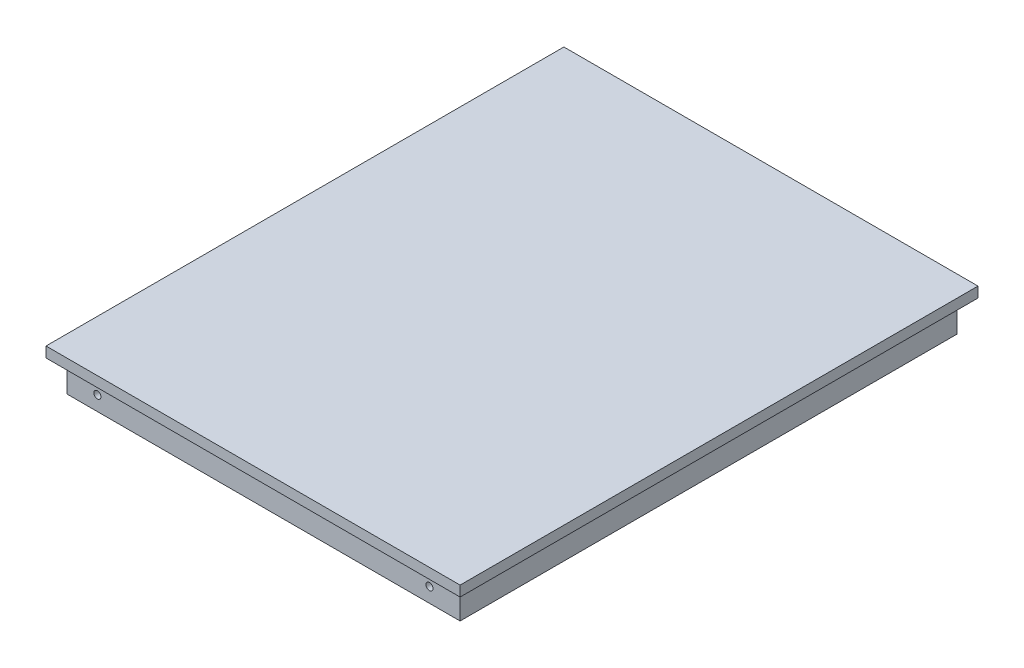
from build123d import *

# Parameters (mm, degrees)
SKETCH1_W                     = 199.5
SKETCH1_H                     = 249.5
BOSS_EXTRUDE1_DEPTH           = 5
SKETCH1_3_W                   = 189.5
SKETCH1_3_H                   = 239.5
SKETCH1_3_W_2                 = 179.5
SKETCH1_3_H_2                 = 229.5
BOSS_EXTRUDE2_DEPTH           = 15
M3_CLEARANCE_HOLE1_AT_2_COUNT = 2
M3_CLEARANCE_HOLE1_AT_2_PITCH = 160


with BuildPart() as part:
    # Sketch1 → Boss-Extrude1 (new body)
    with BuildSketch(Plane(origin=(0, 0, 0), x_dir=(1, 0, 0), z_dir=(0, 1, 0))):
        Rectangle(SKETCH1_W, SKETCH1_H)
    extrude(amount=BOSS_EXTRUDE1_DEPTH)

    # Sketch1_3 → Boss-Extrude2 (add)
    with BuildSketch(Plane(origin=(0, 0, 0), x_dir=(1, 0, 0), z_dir=(0, 1, 0))):
        Rectangle(SKETCH1_3_W, SKETCH1_3_H)
        Rectangle(SKETCH1_3_W_2, SKETCH1_3_H_2, mode=Mode.SUBTRACT)
    extrude(amount=-BOSS_EXTRUDE2_DEPTH)

    # Sketch4 → M3 Clearance Hole1 (revolve, cut)
    with BuildSketch(Plane(origin=(-80, -8, 0), x_dir=(0, 1, 0), z_dir=(1, 0, 0))):
        Polygon((0, 0), (0, 124.75), (1.7, 124.75), (1.7, 0.025), (1.725, 0), align=None)
    m3_clearance_hole1 = revolve(axis=Axis((-80, -8, -6.35), (0, 0, 1)), mode=Mode.SUBTRACT)

    # M3 Clearance Hole1 at 2: M3 Clearance Hole1 ×2
    with Locations(*[(i * M3_CLEARANCE_HOLE1_AT_2_PITCH, 0, 0) for i in range(1, M3_CLEARANCE_HOLE1_AT_2_COUNT)]):
        add(m3_clearance_hole1, mode=Mode.SUBTRACT)

    # Mirror1: M3 Clearance Hole1 across plane
    add(m3_clearance_hole1.mirror(Plane.XY), mode=Mode.SUBTRACT)

    # Mirror1 copy 1 sketch → Mirror1 copy 1 (revolve, cut)
    with BuildSketch(Plane(origin=(80, -8, 0), x_dir=(0, 1, 0), z_dir=(1, 0, 0))):
        Polygon((0, 0), (0, -124.75), (1.7, -124.75), (1.7, -0.025), (1.725, 0), align=None)
    revolve(axis=Axis((80, -8, 6.35), (0, 0, 1)), mode=Mode.SUBTRACT)


solid = part.part
